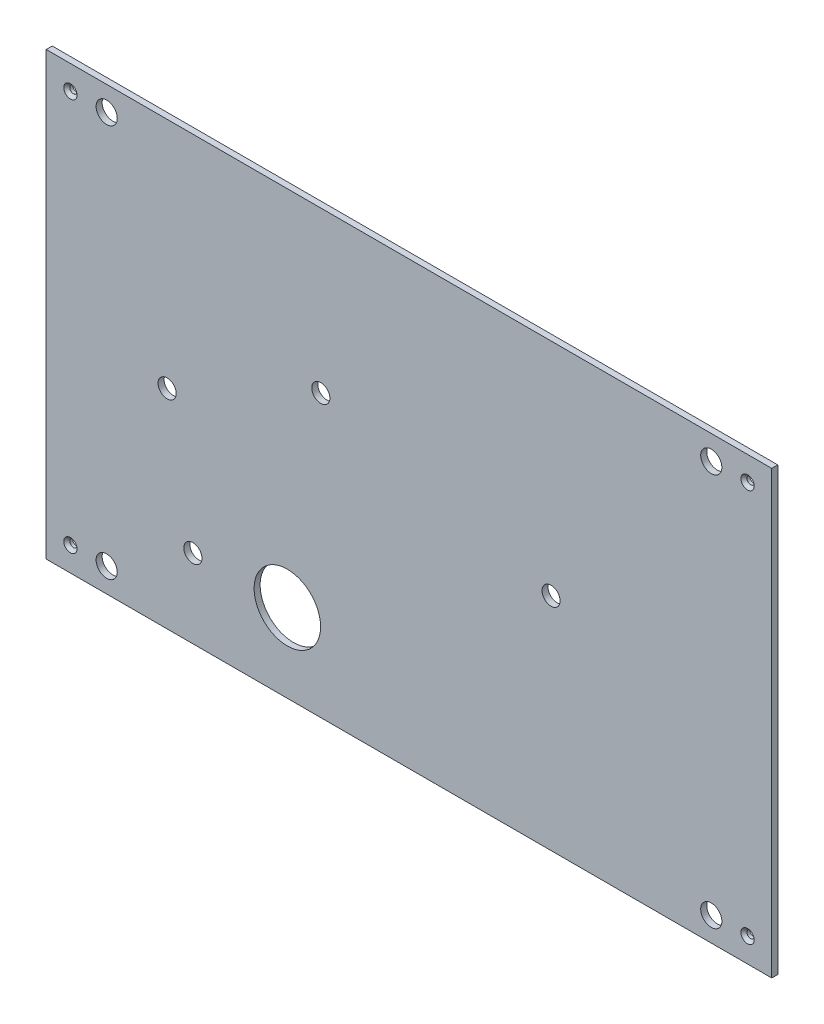
from build123d import *

# Parameters (mm, degrees)
SKETCH_1_W                 = 240
SKETCH_1_H                 = 146
SKETCH_1_R                 = 11
SKETCH_1_R_2               = 3
SKETCH_1_R_3               = 3.5
EXTRUDE_1_DEPTH            = 2
HOLE_WIZARD_M22_AT_2_COUNT = 2
HOLE_WIZARD_M22_AT_2_PITCH = 224
HOLE_WIZARD_M22_AT_3_COUNT = 2
HOLE_WIZARD_M22_AT_3_PITCH = 258.99034731
HOLE_WIZARD_M22_AT_4_COUNT = 2
HOLE_WIZARD_M22_AT_4_PITCH = 130


with BuildPart() as part:
    # Эскиз1 → Бобышка-Вытянуть1 (new body)
    with BuildSketch(Plane.XY):
        with Locations((120, 73)):
            Rectangle(SKETCH_1_W, SKETCH_1_H)
        with Locations((79.765350749, 26)):
            Circle(SKETCH_1_R, mode=Mode.SUBTRACT)
        with Locations((48.515350749, 26)):
            Circle(SKETCH_1_R_2, mode=Mode.SUBTRACT)
        with Locations((167, 73)):
            Circle(SKETCH_1_R_2, mode=Mode.SUBTRACT)
        with Locations((90.832011317, 93)):
            Circle(SKETCH_1_R_2, mode=Mode.SUBTRACT)
        with Locations((40, 68.913299822)):
            Circle(SKETCH_1_R_2, mode=Mode.SUBTRACT)
        with Locations((20, 138)):
            Circle(SKETCH_1_R_3, mode=Mode.SUBTRACT)
        with Locations((220, 138)):
            Circle(SKETCH_1_R_3, mode=Mode.SUBTRACT)
        with Locations((220, 8)):
            Circle(SKETCH_1_R_3, mode=Mode.SUBTRACT)
        with Locations((20, 8)):
            Circle(SKETCH_1_R_3, mode=Mode.SUBTRACT)
    extrude(amount=EXTRUDE_1_DEPTH)

    # Эскиз7 → Зенковка для винта с полупотайной головкой M22 (revolve, cut)
    with BuildSketch(Plane(origin=(8, 138, 2), x_dir=(0, -1, 0), z_dir=(1, 0, 0))):
        Polygon((0, 0), (0, 2), (1.2, 2), (1.2, 1), (2.2, 0), align=None)
    hole_wizard_m22 = revolve(axis=Axis((8, 138, 8.35), (0, 0, -1)), mode=Mode.SUBTRACT)

    # Зенковка для винта с полупотайной головкой M22 at 2: Зенковка для винта с полупотайной головкой M22 ×2
    with Locations(*[(i * HOLE_WIZARD_M22_AT_2_PITCH, 0, 0) for i in range(1, HOLE_WIZARD_M22_AT_2_COUNT)]):
        add(hole_wizard_m22, mode=Mode.SUBTRACT)

    # Зенковка для винта с полупотайной головкой M22 at 3: Зенковка для винта с полупотайной головкой M22 ×2
    with Locations(*[Vector(0.864897099, -0.501949209, 0) * (i * HOLE_WIZARD_M22_AT_3_PITCH) for i in range(1, HOLE_WIZARD_M22_AT_3_COUNT)]):
        add(hole_wizard_m22, mode=Mode.SUBTRACT)

    # Зенковка для винта с полупотайной головкой M22 at 4: Зенковка для винта с полупотайной головкой M22 ×2
    with Locations(*[(0, -i * HOLE_WIZARD_M22_AT_4_PITCH, 0) for i in range(1, HOLE_WIZARD_M22_AT_4_COUNT)]):
        add(hole_wizard_m22, mode=Mode.SUBTRACT)


solid = part.part
